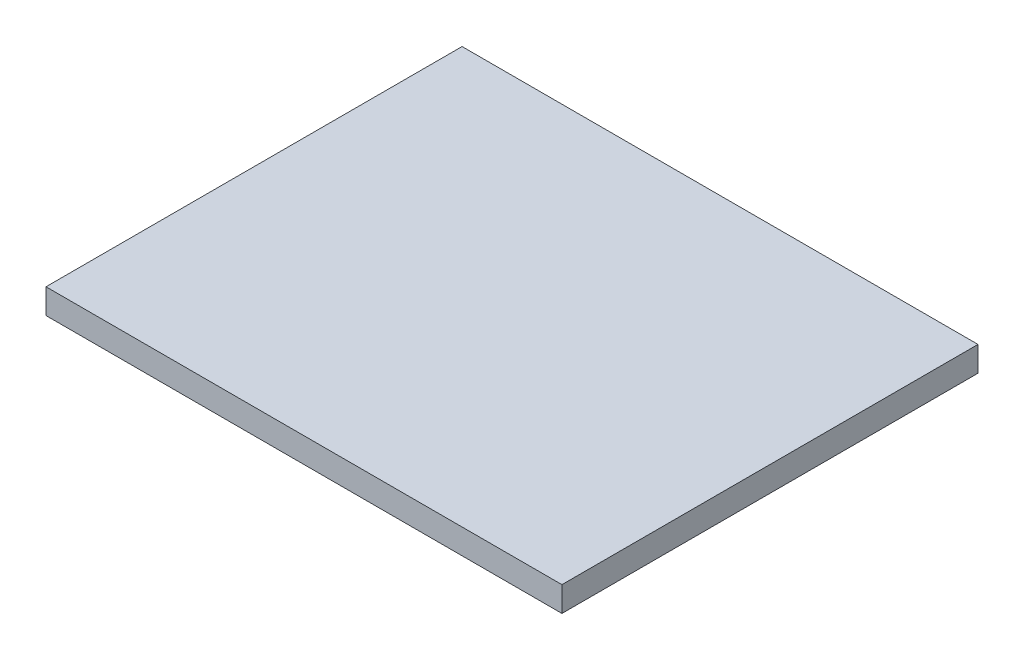
from build123d import *

# Parameters (mm, degrees)
ESQUISSE1_W        = 310
ESQUISSE1_H        = 250
BOSS_EXTRU_1_DEPTH = 15


with BuildPart() as part:
    # Esquisse1 → Boss.-Extru.1 (new body)
    with BuildSketch(Plane(origin=(0, 0, 0), x_dir=(1, 0, 0), z_dir=(0, 1, 0))):
        Rectangle(ESQUISSE1_W, ESQUISSE1_H)
    extrude(amount=BOSS_EXTRU_1_DEPTH)


solid = part.part
